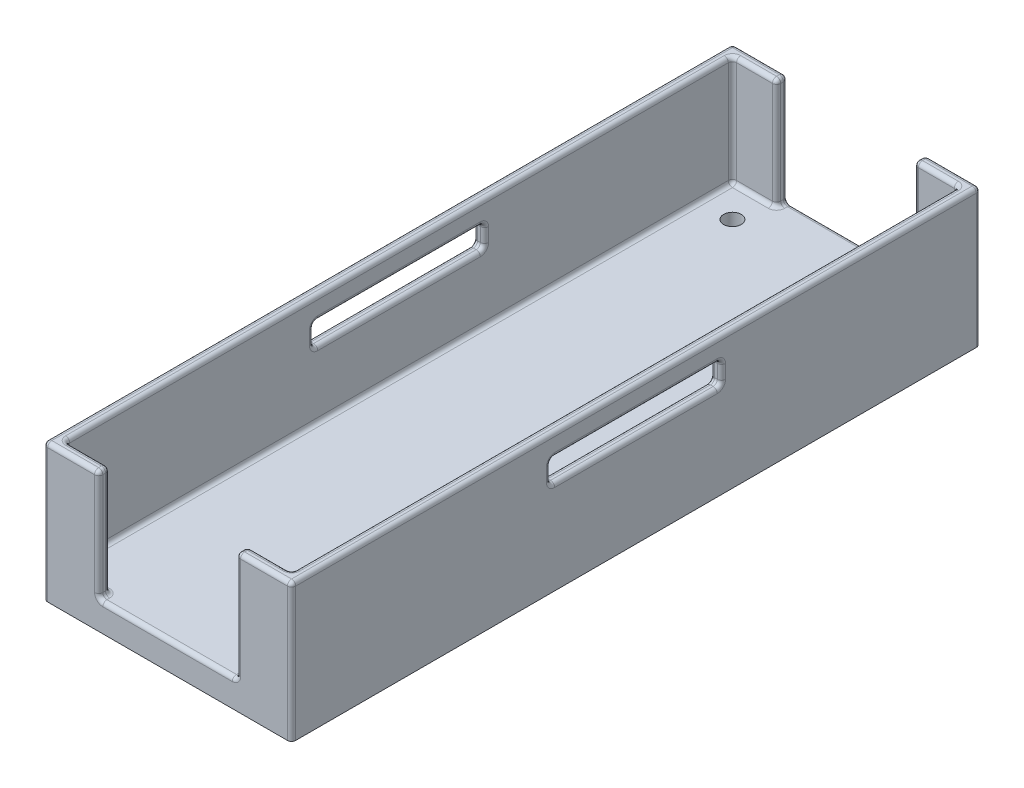
from build123d import *

# Parameters (mm, degrees)
SKETCH1_W           = 45
SKETCH1_H           = 125
BOSS_EXTRUDE1_DEPTH = 25
SKETCH2_W           = 41
SKETCH2_H           = 121
CUT_EXTRUDE1_DEPTH  = 20
SKETCH3_W           = 25
SKETCH3_H           = 20
CUT_EXTRUDE2_DEPTH  = 152
SKETCH4_W           = 31
SKETCH4_H           = 4
CUT_EXTRUDE3_DEPTH  = 126
FILLET1_R           = 0.75
FILLET2_R           = 0.75
SKETCH5_R           = 1.6
CUT_EXTRUDE4_DEPTH  = 10


with BuildPart() as part:
    # Sketch1 → Boss-Extrude1 (new body)
    with BuildSketch(Plane(origin=(0, 0, 0), x_dir=(1, 0, 0), z_dir=(0, 1, 0))):
        with Locations((22.5, 62.5)):
            Rectangle(SKETCH1_W, SKETCH1_H)
    extrude(amount=BOSS_EXTRUDE1_DEPTH)

    # Sketch2 → Cut-Extrude1 (cut)
    with BuildSketch(Plane(origin=(0, 25, 0), x_dir=(1, 0, 0), z_dir=(0, 1, 0))):
        with Locations((22.5, 62.5)):
            Rectangle(SKETCH2_W, SKETCH2_H)
    extrude(amount=-CUT_EXTRUDE1_DEPTH, mode=Mode.SUBTRACT)

    # Sketch3 → Cut-Extrude2 (cut)
    with BuildSketch(Plane.XY):
        with Locations((22.5, 15)):
            Rectangle(SKETCH3_W, SKETCH3_H)
    extrude(amount=-CUT_EXTRUDE2_DEPTH, mode=Mode.SUBTRACT)

    # Sketch4 → Cut-Extrude3 (cut)
    with BuildSketch(Plane.ZY):
        with Locations((-62.5, 19)):
            Rectangle(SKETCH4_W, SKETCH4_H)
    extrude(amount=-CUT_EXTRUDE3_DEPTH, mode=Mode.SUBTRACT)

    # Fillet1
    fillet1_edges = [part.edges().sort_by_distance(p)[0] for p in [
        (43, 17, -62.5),
        (43, 19, -47),
        (43, 21, -62.5),
        (43, 19, -78),
        (45, 19, -78),
        (44, 17, -78),
        (2, 19, -78),
        (1, 17, -78),
        (45, 21, -62.5),
        (44, 21, -78),
        (2, 21, -62.5),
        (1, 21, -78),
        (45, 19, -47),
        (44, 21, -47),
        (2, 19, -47),
        (1, 21, -47),
        (45, 17, -62.5),
        (44, 17, -47),
        (2, 17, -62.5),
        (1, 17, -47),
        (0, 19, -78),
        (0, 17, -62.5),
        (0, 19, -47),
        (0, 21, -62.5),
    ]]
    fillet(fillet1_edges, radius=FILLET1_R)

    # Fillet2
    fillet2_edges = [part.edges().sort_by_distance(p)[0] for p in [
        (45, 25, -62.5),
        (2, 5, -62.5),
        (2, 15, -2),
        (39, 5, -123),
        (2, 15, -123),
        (43, 5, -62.5),
        (40, 25, -125),
        (43, 15, -123),
        (6, 5, -2),
        (43, 15, -2),
        (2, 25, -62.5),
        (6, 25, -2),
        (43, 25, -62.5),
        (39, 25, -123),
        (39, 5, -2),
        (6, 5, -123),
        (39, 25, -2),
        (6, 25, -123),
        (40, 25, 0),
        (5, 25, -125),
        (10, 25, -124),
        (10, 25, -1),
        (22.5, 5, -125),
        (35, 5, -124),
        (35, 5, -1),
        (10, 15, -125),
        (10, 5, -124),
        (10, 15, -123),
        (10, 15, -2),
        (10, 5, -1),
        (35, 15, -125),
        (35, 25, -124),
        (35, 15, -123),
        (35, 15, -2),
        (35, 25, -1),
        (10, 15, 0),
        (22.5, 5, 0),
        (35, 15, 0),
        (0, 25, -62.5),
        (0, 12.5, -125),
        (45, 12.5, -125),
        (45, 12.5, 0),
        (0, 12.5, 0),
        (5, 25, 0),
    ]]
    fillet(fillet2_edges, radius=FILLET2_R)

    # Sketch5 → Cut-Extrude4 (cut)
    with BuildSketch(Plane(origin=(0, 5, 0), x_dir=(1, 0, 0), z_dir=(0, 1, 0))):
        with Locations((7.75, 117.25)):
            Circle(SKETCH5_R)
        with Locations((37.25, 7.75)):
            Circle(SKETCH5_R)
    extrude(amount=-CUT_EXTRUDE4_DEPTH, mode=Mode.SUBTRACT)


solid = part.part
